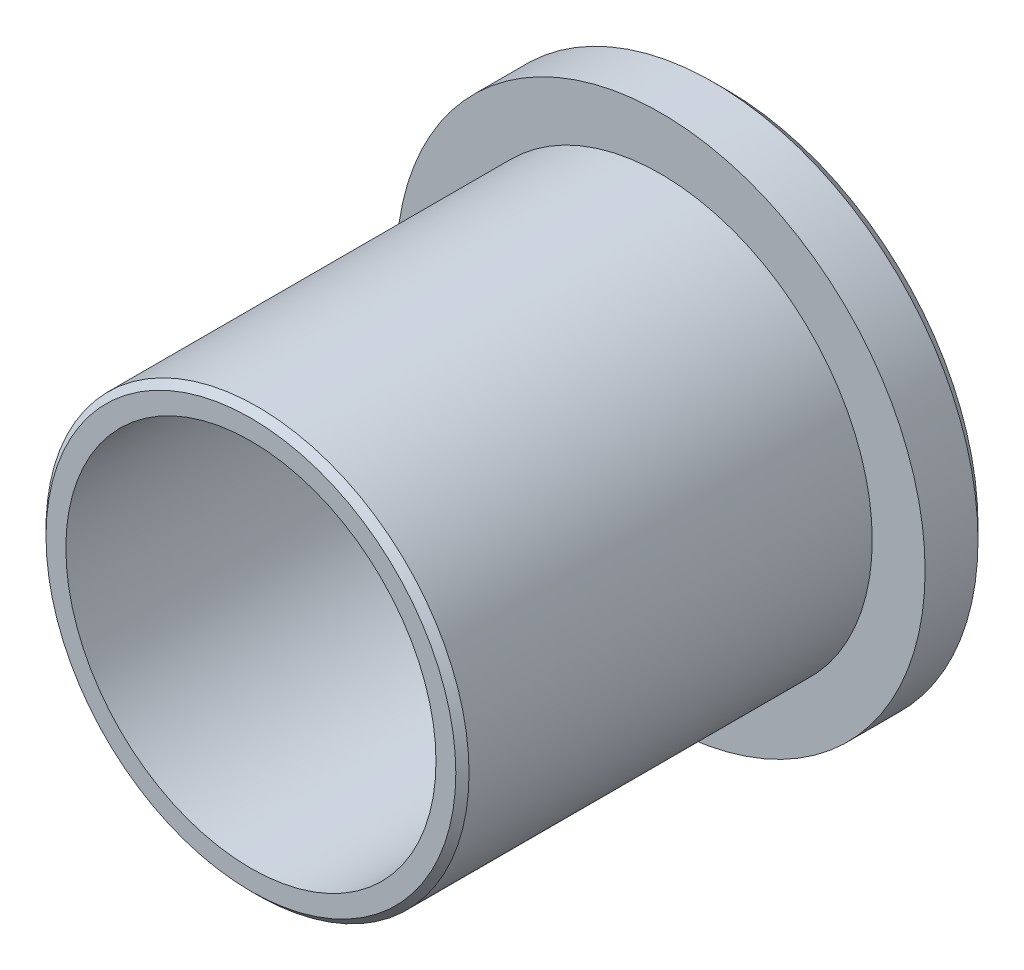
from build123d import *


with BuildPart() as part:
    # Sketch1 → Revolve1 (revolve)
    with BuildSketch(Plane(origin=(0, 0, 0), x_dir=(0, 0, -1), z_dir=(1, 0, 0))):
        Polygon((0, 7), (18, 7), (18, 9.5), (17.5, 10), (15.5, 10), (15.5, 8), (0.25, 8), (0, 7.75), align=None)
    revolve(axis=Axis((0, 0, 0), (0, 0, -1)))


solid = part.part
